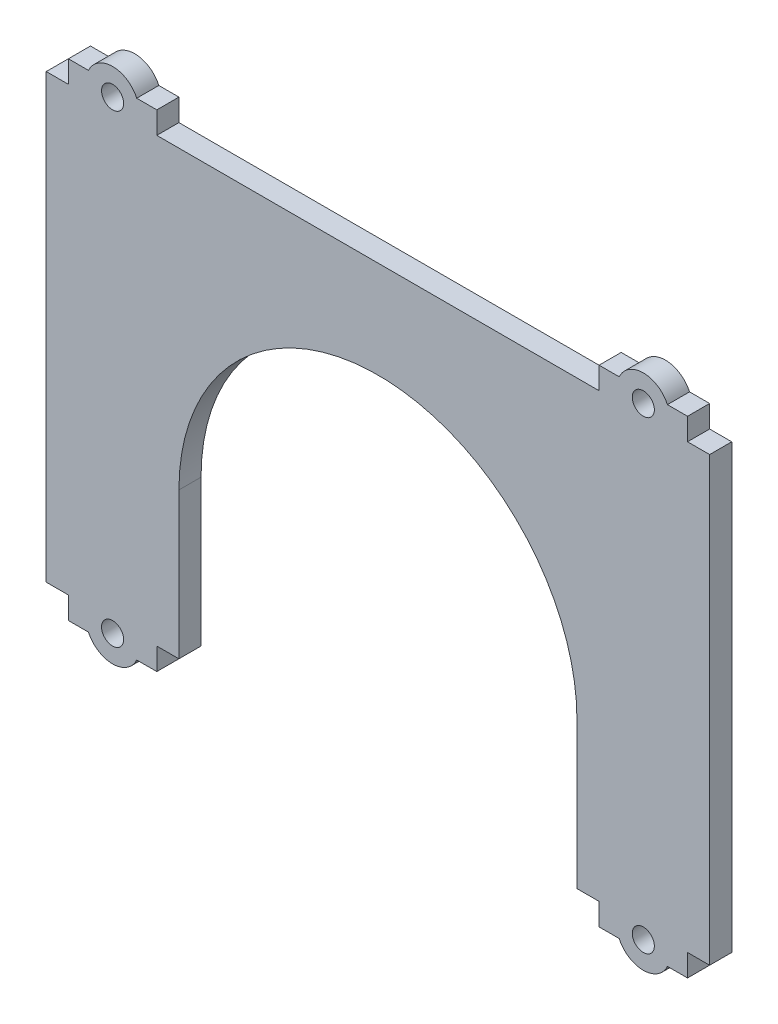
from build123d import *

# Parameters (mm, degrees)
SKETCH1_W                                  = 150
SKETCH1_H                                  = 100
BOSS_EXTRUDE1_DEPTH                        = 5
SKETCH3_W                                  = 20
SKETCH3_H                                  = 5
BOSS_EXTRUDE2_DEPTH                        = 5
MIRROR1_AT_THE_SECOND_PLANE_COPY_1_SKETC_W = 20
MIRROR1_AT_THE_SECOND_PLANE_COPY_1_SKETC_H = 5
MIRROR1_AT_THE_SECOND_PLANE_COPY_1_DEPTH   = 5
SKETCH4_R                                  = 6
BOSS_EXTRUDE3_DEPTH                        = 5
SKETCH5_R                                  = 2.5
CUT_EXTRUDE1_DEPTH                         = 5
MIRROR2_AT_THE_SECOND_PLANE_COPY_1_SKETC_R = 6
MIRROR2_AT_THE_SECOND_PLANE_COPY_1_DEPTH   = 5
MIRROR2_AT_THE_SECOND_PLANE_COPY_2_SKETC_R = 2.5
MIRROR2_AT_THE_SECOND_PLANE_COPY_2_DEPTH   = 5
CUT_EXTRUDE3_DEPTH                         = 1
CUT_EXTRUDE3_DEPTH_BACK                    = 5


with BuildPart() as part:
    # Sketch1 → Boss-Extrude1 (new body)
    with BuildSketch(Plane.XY):
        Rectangle(SKETCH1_W, SKETCH1_H)
    extrude(amount=BOSS_EXTRUDE1_DEPTH)

    # Sketch3 → Boss-Extrude2 (add)
    with BuildSketch(Plane.XZ.offset(50)):
        with Locations((-60, 2.5)):
            Rectangle(SKETCH3_W, SKETCH3_H)
    boss_extrude2 = extrude(amount=BOSS_EXTRUDE2_DEPTH)

    # Mirror1: Boss-Extrude2 across plane
    add(boss_extrude2.mirror(Plane(origin=(0, 0, 0), x_dir=(0, 0, 1), z_dir=(1, 0, 0))))

    # Mirror1 at the second plane: Boss-Extrude2 across plane
    add(boss_extrude2.mirror(Plane.ZX))

    # Mirror1 at the second plane copy 1 sketc → Mirror1 at the second plane copy 1 (add)
    with BuildSketch(Plane(origin=(0, 50, 0), x_dir=(-1, 0, 0), z_dir=(0, 1, 0))):
        with Locations((-60, 2.5)):
            Rectangle(MIRROR1_AT_THE_SECOND_PLANE_COPY_1_SKETC_W, MIRROR1_AT_THE_SECOND_PLANE_COPY_1_SKETC_H)
    extrude(amount=MIRROR1_AT_THE_SECOND_PLANE_COPY_1_DEPTH)

    # Sketch4 → Boss-Extrude3 (add)
    with BuildSketch(Plane.XY.offset(5)):
        with Locations((60, 52.5)):
            Circle(SKETCH4_R)
    boss_extrude3 = extrude(amount=-BOSS_EXTRUDE3_DEPTH)

    # Sketch5 → Cut-Extrude1 (cut)
    with BuildSketch(Plane.XY.offset(5)):
        with Locations((60, 52.5)):
            Circle(SKETCH5_R)
    cut_extrude1 = extrude(amount=-CUT_EXTRUDE1_DEPTH, mode=Mode.SUBTRACT)

    # Mirror2: Boss-Extrude3, Cut-Extrude1 across plane
    add(boss_extrude3.mirror(Plane(origin=(0, 0, 0), x_dir=(0, 0, 1), z_dir=(1, 0, 0))))
    add(cut_extrude1.mirror(Plane(origin=(0, 0, 0), x_dir=(0, 0, 1), z_dir=(1, 0, 0))), mode=Mode.SUBTRACT)

    # Mirror2 at the second plane: Boss-Extrude3, Cut-Extrude1 across plane
    add(boss_extrude3.mirror(Plane.ZX))
    add(cut_extrude1.mirror(Plane.ZX), mode=Mode.SUBTRACT)

    # Mirror2 at the second plane copy 1 sketc → Mirror2 at the second plane copy 1 (add)
    with BuildSketch(Plane(origin=(0, 0, 5), x_dir=(-1, 0, 0), z_dir=(0, 0, 1))):
        with Locations((60, 52.5)):
            Circle(MIRROR2_AT_THE_SECOND_PLANE_COPY_1_SKETC_R)
    extrude(amount=-MIRROR2_AT_THE_SECOND_PLANE_COPY_1_DEPTH)

    # Mirror2 at the second plane copy 2 sketc → Mirror2 at the second plane copy 2 (cut)
    with BuildSketch(Plane(origin=(0, 0, 5), x_dir=(-1, 0, 0), z_dir=(0, 0, 1))):
        with Locations((60, 52.5)):
            Circle(MIRROR2_AT_THE_SECOND_PLANE_COPY_2_SKETC_R)
    extrude(amount=-MIRROR2_AT_THE_SECOND_PLANE_COPY_2_DEPTH, mode=Mode.SUBTRACT)

    # Sketch8 → Cut-Extrude3 (cut, two sides)
    with BuildSketch(Plane.XY.offset(5)) as cut_extrude3_sk:
        with BuildLine():
            Line((45, -383.556795633), (45, -50))
            Line((45, -50), (45, -16.928023383))
            ThreePointArc((45, -16.928023383), (0, 28.071976617), (-45, -16.928023383))
            Line((-45, -16.928023383), (-45, -50))
            Line((-45, -50), (-45, -383.556795633))
            Line((-45, -383.556795633), (-45, -1050.670386898))
            Line((-45, -1050.670386898), (45, -1050.670386898))
            Line((45, -1050.670386898), (45, -383.556795633))
        make_face()
    extrude(amount=CUT_EXTRUDE3_DEPTH, mode=Mode.SUBTRACT)
    extrude(cut_extrude3_sk.sketch, amount=-CUT_EXTRUDE3_DEPTH_BACK, mode=Mode.SUBTRACT)


solid = part.part
